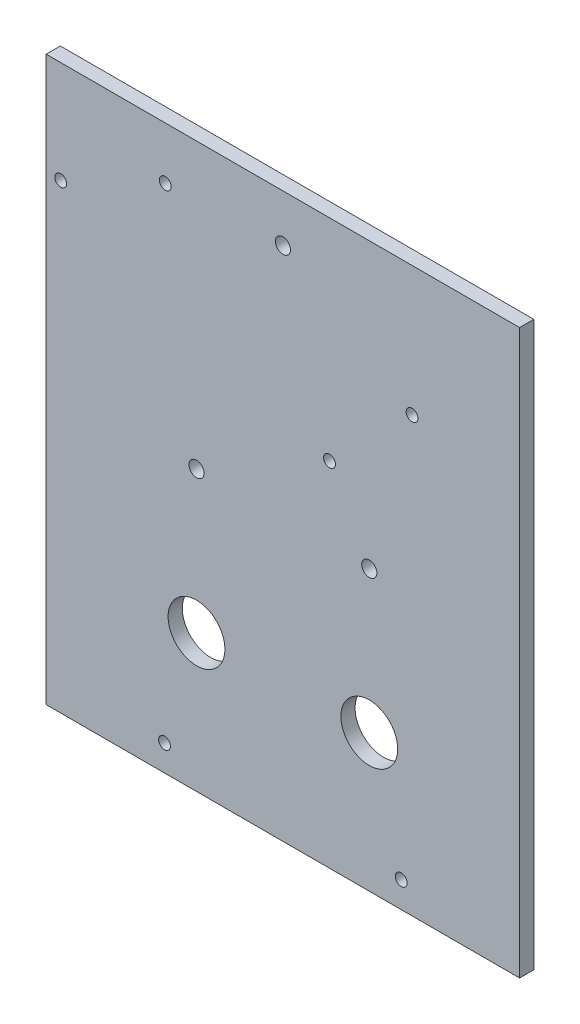
from build123d import *

# Parameters (mm, degrees)
SKETCH_1_W          = 100
SKETCH_1_H          = 120
SKETCH_1_R          = 1.6
SKETCH_1_R_2        = 1.7
EXTRUDE_1_DEPTH     = 3
SKETCH_2_R          = 6
CUT_EXTRUDE_1_DEPTH = 3
SKETCH_3_R          = 1.6
CUT_EXTRUDE_2_DEPTH = 3
SKETCH_5_R          = 1.6
CUT_EXTRUDE_4_DEPTH = 10
SKETCH_6_W          = 100
SKETCH_6_H          = 3
CUT_EXTRUDE_5_DEPTH = 1
M3X0_5_2_D          = 2.5
M3X0_5_2_DEPTH      = 8.5
M3X0_5_2_TIP        = 0.751075774
M3X0_5_4_D          = 2.5
M3X0_5_4_DEPTH      = 8.5
M3X0_5_4_TIP        = 0.751075774


with BuildPart() as part:
    # ｽｹｯﾁ1 → ﾎﾞｽ - 押し出し1 (new body)
    with BuildSketch(Plane.XY):
        Rectangle(SKETCH_1_W, SKETCH_1_H)
        with Locations((27.323825812, 32.591356486)):
            Circle(SKETCH_1_R, mode=Mode.SUBTRACT)
        with Locations((9.838236374, 15.468735133)):
            Circle(SKETCH_1_R, mode=Mode.SUBTRACT)
        with Locations((-24.839988255, 48.970021629)):
            Circle(SKETCH_1_R, mode=Mode.SUBTRACT)
        with Locations((-46.955532443, 38.489911645)):
            Circle(SKETCH_1_R_2, mode=Mode.SUBTRACT)
        with Locations((-46.955532443, 38.489911645)):
            Circle(SKETCH_1_R_2)
        with Locations((-24.839988255, 48.970021629)):
            Circle(SKETCH_1_R)
        with Locations((9.838236374, 15.468735133)):
            Circle(SKETCH_1_R)
        with Locations((27.323825812, 32.591356486)):
            Circle(SKETCH_1_R)
    extrude(amount=EXTRUDE_1_DEPTH)

    # ｽｹｯﾁ2 → ｶｯﾄ - 押し出し1 (cut)
    with BuildSketch(Plane.XY.offset(3)):
        with Locations((18.25, -30)):
            Circle(SKETCH_2_R)
        with Locations((-18.25, -30)):
            Circle(SKETCH_2_R)
    extrude(amount=-CUT_EXTRUDE_1_DEPTH, mode=Mode.SUBTRACT)

    # ｽｹｯﾁ3 → ｶｯﾄ - 押し出し2 (cut)
    with BuildSketch(Plane.XY.offset(3)):
        with Locations((18.25, 0)):
            Circle(SKETCH_3_R)
        with Locations((-18.25, 0)):
            Circle(SKETCH_3_R)
    extrude(amount=-CUT_EXTRUDE_2_DEPTH, mode=Mode.SUBTRACT)

    # ｽｹｯﾁ5 → ｶｯﾄ - 押し出し4 (cut)
    with BuildSketch(Plane.XY.offset(3)):
        with Locations((0, 50)):
            Circle(SKETCH_5_R)
    extrude(amount=-CUT_EXTRUDE_4_DEPTH, mode=Mode.SUBTRACT)

    # ｽｹｯﾁ6 → ｶｯﾄ - 押し出し5 (cut)
    with BuildSketch(Plane(origin=(0, -60, 0), x_dir=(-1, 0, 0), z_dir=(0, -1, 0))):
        with Locations((0, -1.5)):
            Rectangle(SKETCH_6_W, SKETCH_6_H)
    extrude(amount=-CUT_EXTRUDE_5_DEPTH, mode=Mode.SUBTRACT)

    # M3x0.5 ねじ穴2
    with Locations(Plane(origin=(-24.853088108, 48.954010468, 0), x_dir=(-1, 0, 0), z_dir=(0, 0, -1))):
        with Locations((0, 0), (-52.138387466, -16.325171933), (-34.696786927, -33.443354168), (22.086677003, -10.506105498)):
            Hole(M3X0_5_2_D / 2, depth=M3X0_5_2_DEPTH)
            with Locations((0, 0, -(M3X0_5_2_DEPTH + M3X0_5_2_TIP / 2))):  # 118° drill point
                Cone(0, M3X0_5_2_D / 2, M3X0_5_2_TIP, mode=Mode.SUBTRACT)

    # M3x0.5 ねじ穴4
    with Locations(Plane(origin=(-25.000041654, -53.500009307, 3), x_dir=(1, 0, 0), z_dir=(0, 0, 1))):
        with Locations((0, 0), (4.1654e-05, 9.307e-06), (49.994493901, -0.014222141)):
            Hole(M3X0_5_4_D / 2, depth=M3X0_5_4_DEPTH)
            with Locations((0, 0, -(M3X0_5_4_DEPTH + M3X0_5_4_TIP / 2))):  # 118° drill point
                Cone(0, M3X0_5_4_D / 2, M3X0_5_4_TIP, mode=Mode.SUBTRACT)


solid = part.part
